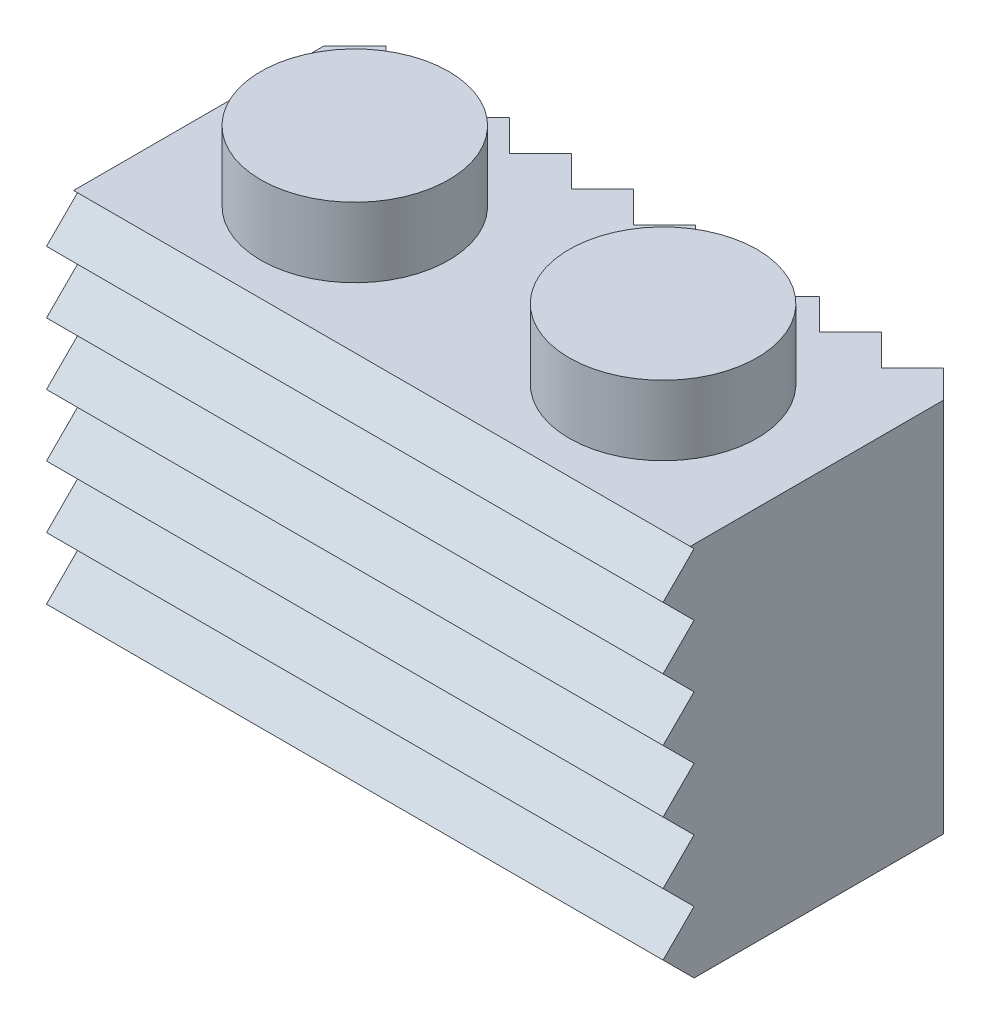
from build123d import *

# Parameters (mm, degrees)
SKETCH1_W       = 7.96
SKETCH1_H       = 7.96
EXTRUDE1_DEPTH  = 9.7
SKETCH2_R       = 2.425
EXTRUDE2_DEPTH  = 1.8
LPATTERN1_COUNT = 2
LPATTERN1_PITCH = 7.96
SHELL1_T        = -1.55
SKETCH3_W       = 12.82
SKETCH3_H       = 4.86
EXTRUDE3_DEPTH  = 0.14
SKETCH4_R       = 1.5
EXTRUDE4_DEPTH  = 8.29
SKETCH5_W       = 1
SKETCH5_H       = 4.86
EXTRUDE5_DEPTH  = 6.29
EXTRUDE6_DEPTH  = 16.92
LPATTERN2_COUNT = 7
LPATTERN2_PITCH = 1.6
EXTRUDE7_DEPTH  = 10.7
LPATTERN3_COUNT = 11
LPATTERN3_PITCH = 1.6


with BuildPart() as part:
    # Sketch1 → Extrude1 (new body)
    with BuildSketch(Plane(origin=(0, 0, 0), x_dir=(1, 0, 0), z_dir=(0, 1, 0))):
        Rectangle(SKETCH1_W, SKETCH1_H)
    extrude1 = extrude(amount=EXTRUDE1_DEPTH)

    # Sketch2 → Extrude2 (add)
    with BuildSketch(Plane(origin=(0, 9.7, 0), x_dir=(1, 0, 0), z_dir=(0, 1, 0))):
        Circle(SKETCH2_R)
    extrude2 = extrude(amount=EXTRUDE2_DEPTH)

    # LPattern1: Extrude1, Extrude2 ×2
    with Locations(*[(i * LPATTERN1_PITCH, 0, 0) for i in range(1, LPATTERN1_COUNT)]):
        add(extrude1)
        add(extrude2)

    # Shell1
    shell1_openings = [part.faces().sort_by_distance(p)[0] for p in [
        (3.98, 0, 0),
    ]]
    offset(amount=SHELL1_T, openings=shell1_openings, kind=Kind.INTERSECTION)

    # Sketch3 → Extrude3 (cut)
    with BuildSketch(Plane.XZ.offset(-8.15)):
        with Locations((3.98, 0)):
            Rectangle(SKETCH3_W, SKETCH3_H)
    extrude(amount=-EXTRUDE3_DEPTH, mode=Mode.SUBTRACT)

    # Sketch4 → Extrude4 (add)
    with BuildSketch(Plane.XZ.offset(-8.29)):
        with Locations((3.98, 0)):
            Circle(SKETCH4_R)
    extrude(amount=EXTRUDE4_DEPTH)

    # Sketch5 → Extrude5 (add)
    with BuildSketch(Plane.XZ.offset(-8.29)):
        with Locations((3.98, 0)):
            Rectangle(SKETCH5_W, SKETCH5_H)
    extrude(amount=EXTRUDE5_DEPTH)

    # Sketch7 → Extrude6 (cut, through all)
    with BuildSketch(Plane(origin=(11.94, 0, 0), x_dir=(0, 0, -1), z_dir=(1, 0, 0))):
        Polygon((-3.98, -0.8), (-3.18, 0), (-3.98, 0.8), align=None)
    extrude6 = extrude(amount=-EXTRUDE6_DEPTH, mode=Mode.SUBTRACT)

    # LPattern2: Extrude6 ×7
    with Locations(*[(0, i * LPATTERN2_PITCH, 0) for i in range(1, LPATTERN2_COUNT)]):
        add(extrude6, mode=Mode.SUBTRACT)

    # Sketch8 → Extrude7 (cut, through all)
    with BuildSketch(Plane(origin=(0, 9.7, 0), x_dir=(1, 0, 0), z_dir=(0, 1, 0))):
        Polygon((-3.98, 3.18), (-3.18, 3.98), (-4.78, 3.98), align=None)
    extrude7 = extrude(amount=-EXTRUDE7_DEPTH, mode=Mode.SUBTRACT)

    # LPattern3: Extrude7 ×11
    with Locations(*[(i * LPATTERN3_PITCH, 0, 0) for i in range(1, LPATTERN3_COUNT)]):
        add(extrude7, mode=Mode.SUBTRACT)


solid = part.part
